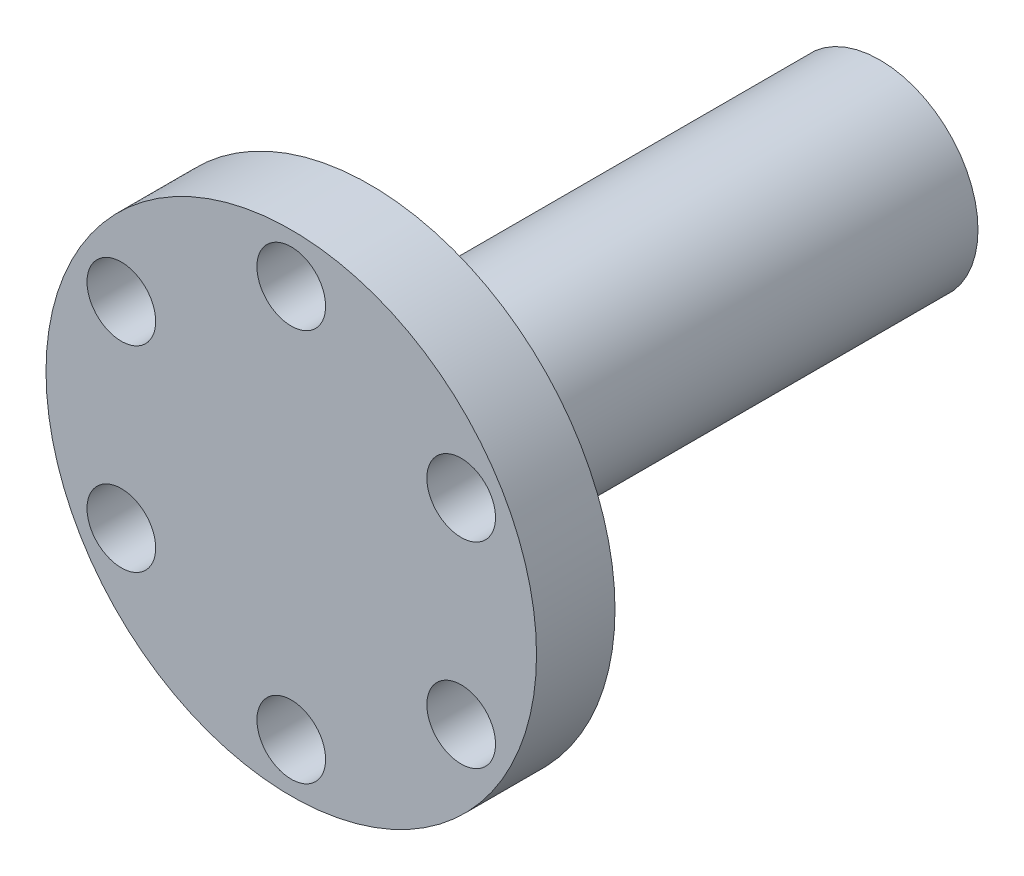
from build123d import *

# Parameters (mm, degrees)
SKETCH_1_W          = 7.5
SKETCH_1_H          = 4
SKETCH_2_R          = 1.75
CUT_EXTRUDE_1_DEPTH = 5


with BuildPart() as part:
    # 草圖1 → 旋轉1 (revolve)
    with BuildSketch(Plane(origin=(0, 0, 0), x_dir=(1, 0, 0), z_dir=(0, 1, 0))):
        Polygon((0, 30), (0, 0), (5, 0), (5, 4), (5, 30), align=None)
        with Locations((8.75, 2)):
            Rectangle(SKETCH_1_W, SKETCH_1_H)
    revolve(axis=Axis((0, 0, 0), (0, 0, -1)))

    # 草圖2 → 除料-伸長1 (cut, through all)
    with BuildSketch(Plane(origin=(0, 0, -4), x_dir=(-1, 0, 0), z_dir=(0, 0, -1))):
        with Locations((0, 10)):
            Circle(SKETCH_2_R)
        with Locations((8.660254038, 5)):
            Circle(SKETCH_2_R)
        with Locations((8.660254038, -5)):
            Circle(SKETCH_2_R)
        with Locations((0, -10)):
            Circle(SKETCH_2_R)
        with Locations((-8.660254038, -5)):
            Circle(SKETCH_2_R)
        with Locations((-8.660254038, 5)):
            Circle(SKETCH_2_R)
    extrude(amount=-CUT_EXTRUDE_1_DEPTH, mode=Mode.SUBTRACT)


solid = part.part
